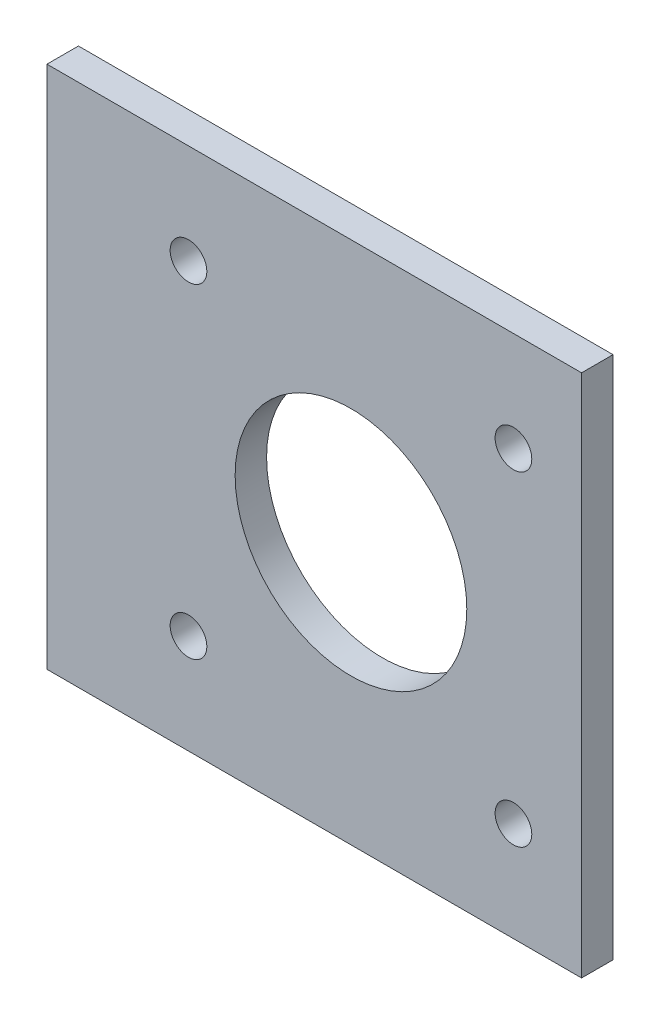
from build123d import *

# Parameters (mm, degrees)
CROQUIS1_W              = 51
CROQUIS1_H              = 50
CROQUIS1_R              = 11.05
CROQUIS1_R_2            = 1.75
SALIENTE_EXTRUIR1_DEPTH = 3


with BuildPart() as part:
    # Croquis1 → Saliente-Extruir1 (new body)
    with BuildSketch(Plane.XY):
        with Locations((25.5, -25)):
            Rectangle(CROQUIS1_W, CROQUIS1_H)
        with Locations((29, -25)):
            Circle(CROQUIS1_R, mode=Mode.SUBTRACT)
        with Locations((44.5, -40.5)):
            Circle(CROQUIS1_R_2, mode=Mode.SUBTRACT)
        with Locations((13.5, -40.5)):
            Circle(CROQUIS1_R_2, mode=Mode.SUBTRACT)
        with Locations((13.5, -9.5)):
            Circle(CROQUIS1_R_2, mode=Mode.SUBTRACT)
        with Locations((44.5, -9.5)):
            Circle(CROQUIS1_R_2, mode=Mode.SUBTRACT)
    extrude(amount=SALIENTE_EXTRUIR1_DEPTH)


solid = part.part
